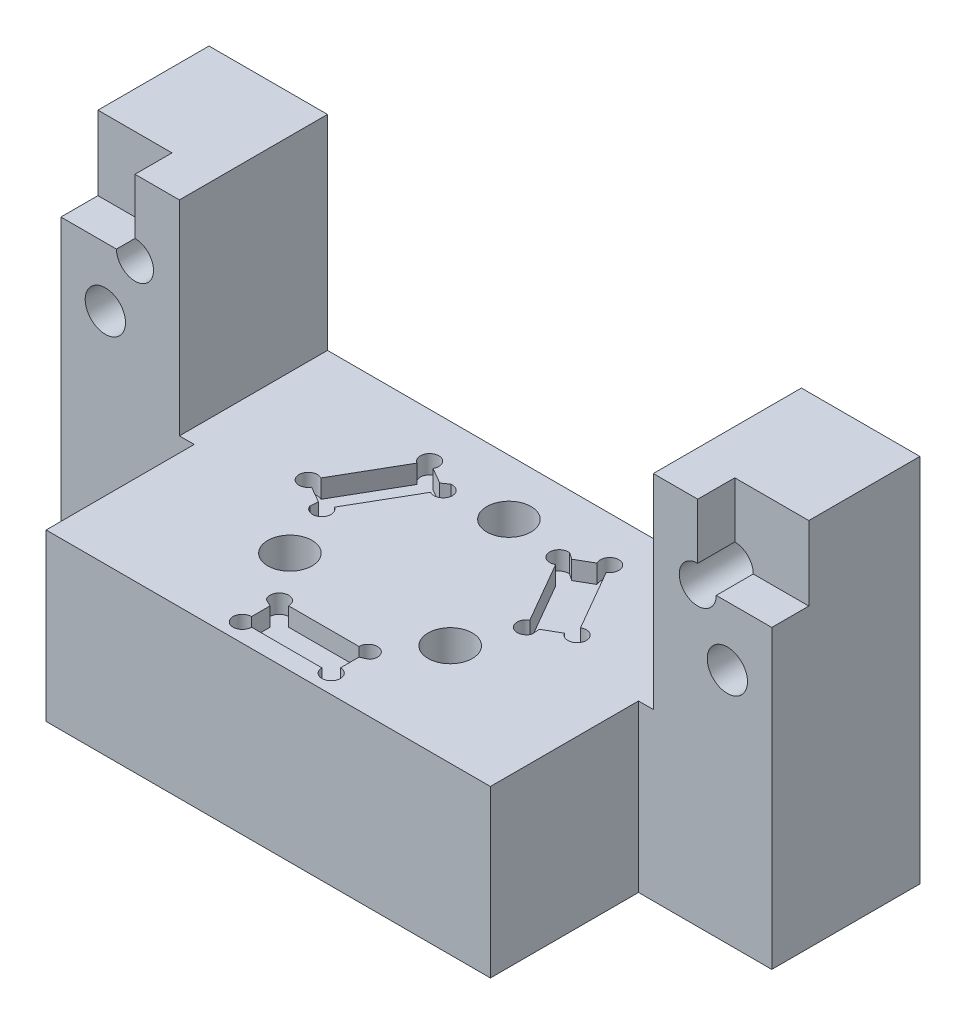
from build123d import *

# Parameters (mm, degrees)
SKETCH1_W                                      = 60.96
SKETCH1_H                                      = 31.75
BOSS_EXTRUDE1_DEPTH                            = 12.7
CUT_EXTRUDE2_REACH                             = 27.4
SKETCH4_W                                      = 40.64
SKETCH4_H                                      = 17.526
SKETCH5_W                                      = 11.43
SKETCH5_H                                      = 31.75
CUT_EXTRUDE3_DEPTH                             = 12.7
SKETCH6_W                                      = 6.35
SKETCH6_H                                      = 6.35
CUT_EXTRUDE4_DEPTH                             = 3.175
SKETCH7_R                                      = 1.5875
CUT_EXTRUDE5_DEPTH                             = 6.35
F_8_32_TAPPED_HOLE1_D                          = 3.4544
F_8_32_TAPPED_HOLE1_DEPTH                      = 12.701
CUT_EXTRUDE7_DEPTH                             = 1.5875
CBORE_FOR_6_SOCKET_HEAD_CAP_SCREW1_D           = 3.7973
CBORE_FOR_6_SOCKET_HEAD_CAP_SCREW1_CBORE_D     = 7.14502
CBORE_FOR_6_SOCKET_HEAD_CAP_SCREW1_CBORE_DEPTH = 3.5052


with BuildPart() as part:
    # Sketch1 → Boss-Extrude1 (new body, symmetric)
    with BuildSketch(Plane.XY):
        Rectangle(SKETCH1_W, SKETCH1_H)
    extrude(amount=BOSS_EXTRUDE1_DEPTH, both=True)

    # Sketch4 → Cut-Extrude2 (cut, up to next)
    with BuildSketch(Plane.XY.offset(12.7), mode=Mode.PRIVATE) as cut_extrude2_sk1:
        with Locations((0, 7.112)):
            Rectangle(SKETCH4_W, SKETCH4_H)
    cut_extrude2_tool1 = extrude(cut_extrude2_sk1.sketch, amount=-CUT_EXTRUDE2_REACH, mode=Mode.PRIVATE) & part.part
    add(cut_extrude2_tool1.solids().sort_by_distance((0, 7.112, 12.7))[0], mode=Mode.SUBTRACT)

    # Sketch5 → Cut-Extrude3 (cut)
    with BuildSketch(Plane.XY.offset(12.7)):
        with Locations((24.765, 0)):
            Rectangle(SKETCH5_W, SKETCH5_H)
    cut_extrude3 = extrude(amount=-CUT_EXTRUDE3_DEPTH, mode=Mode.SUBTRACT)

    # Mirror2: Cut-Extrude3 across plane
    add(cut_extrude3.mirror(Plane(origin=(0, 0, 0), x_dir=(0, 0, 1), z_dir=(1, 0, 0))), mode=Mode.SUBTRACT)

    # Sketch6 → Cut-Extrude4 (cut)
    with BuildSketch(Plane.XY):
        with Locations((27.305, 12.7)):
            Rectangle(SKETCH6_W, SKETCH6_H)
    cut_extrude4 = extrude(amount=-CUT_EXTRUDE4_DEPTH, mode=Mode.SUBTRACT)

    # Sketch7 → Cut-Extrude5 (cut)
    with BuildSketch(Plane.XY):
        with Locations((24.13, 9.525)):
            Circle(SKETCH7_R)
    cut_extrude5 = extrude(amount=-CUT_EXTRUDE5_DEPTH, mode=Mode.SUBTRACT)

    # #8-32 Tapped Hole1
    with Locations(Plane.XY):
        with Locations((26.67, 4.445)):
            f_8_32_tapped_hole1 = Hole(F_8_32_TAPPED_HOLE1_D / 2, depth=F_8_32_TAPPED_HOLE1_DEPTH)

    # Mirror3: Cut-Extrude4, Cut-Extrude5, #8-32 Tapped Hole1 across plane
    add(cut_extrude4.mirror(Plane(origin=(0, 0, 0), x_dir=(0, 0, 1), z_dir=(1, 0, 0))), mode=Mode.SUBTRACT)
    add(cut_extrude5.mirror(Plane(origin=(0, 0, 0), x_dir=(0, 0, 1), z_dir=(1, 0, 0))), mode=Mode.SUBTRACT)
    add(f_8_32_tapped_hole1.mirror(Plane(origin=(0, 0, 0), x_dir=(0, 0, 1), z_dir=(1, 0, 0))), mode=Mode.SUBTRACT)

    # Sketch13 → Cut-Extrude7 (cut)
    with BuildSketch(Plane(origin=(0, -1.651, 0), x_dir=(1, 0, 0), z_dir=(0, 1, 0))):
        with BuildLine():
            ThreePointArc((-3.01625, -7.9375), (-3.247570925, -8.497600525), (-3.80670694, -8.731243169))
            ThreePointArc((-3.80670694, -8.731243169), (0, -9.525), (3.80670694, -8.731243169))
            ThreePointArc((3.80670694, -8.731243169), (3.247570925, -8.497600525), (3.01625, -7.9375))
            Line((3.01625, -7.9375), (-3.01625, -7.9375))
        make_face()
        with BuildLine():
            ThreePointArc((-3.81, -10.31875), (-3.248733992, -10.551233992), (-3.01625, -11.1125))
            Line((-3.01625, -11.1125), (3.01625, -11.1125))
            ThreePointArc((3.01625, -11.1125), (3.248733992, -10.551233992), (3.81, -10.31875))
            Line((3.81, -10.31875), (3.81, -8.73125))
            ThreePointArc((3.81, -8.73125), (3.808353466, -8.731248292), (3.80670694, -8.731243169))
            ThreePointArc((3.80670694, -8.731243169), (0, -9.525), (-3.80670694, -8.731243169))
            ThreePointArc((-3.80670694, -8.731243169), (-3.808353466, -8.731248292), (-3.81, -8.73125))
            Line((-3.81, -8.73125), (-3.81, -10.31875))
        make_face()
        with BuildLine():
            ThreePointArc((-4.431365232, -8.431407189), (-4.123382809, -8.586229627), (-3.81, -8.729806699))
            Line((-3.81, -8.729806699), (-3.81, -7.9375))
            Line((-3.81, -7.9375), (-3.01625, -7.9375))
            ThreePointArc((-3.01625, -7.9375), (-4.071563004, -7.188084322), (-4.431365232, -8.431407189))
        make_face()
        with BuildLine():
            Line((-3.81, -7.9375), (-3.81, -8.729806699))
            ThreePointArc((-3.81, -8.729806699), (-3.808353538, -8.730525089), (-3.80670694, -8.731243169))
            ThreePointArc((-3.80670694, -8.731243169), (-3.247570925, -8.497600525), (-3.01625, -7.9375))
            Line((-3.01625, -7.9375), (-3.81, -7.9375))
        make_face()
        with BuildLine():
            ThreePointArc((-4.431365232, -8.431407189), (-4.123382809, -8.586229627), (-3.81, -8.729806699))
            Line((-3.81, -8.729806699), (-3.81, -7.9375))
            Line((-3.81, -7.9375), (-3.01625, -7.9375))
            ThreePointArc((-3.01625, -7.9375), (-4.071563004, -7.188084322), (-4.431365232, -8.431407189))
        make_face()
        with BuildLine():
            Line((-3.81, -7.9375), (-3.81, -8.729806699))
            ThreePointArc((-3.81, -8.729806699), (-3.808353538, -8.730525089), (-3.80670694, -8.731243169))
            ThreePointArc((-3.80670694, -8.731243169), (-3.247570925, -8.497600525), (-3.01625, -7.9375))
            Line((-3.01625, -7.9375), (-3.81, -7.9375))
        make_face()
        with BuildLine():
            Line((-3.81, -10.31875), (-3.81, -11.1125))
            Line((-3.81, -11.1125), (-3.01625, -11.1125))
            ThreePointArc((-3.01625, -11.1125), (-3.248733992, -10.551233992), (-3.81, -10.31875))
        make_face()
        with BuildLine():
            Line((-3.01625, -11.1125), (-3.81, -11.1125))
            Line((-3.81, -11.1125), (-3.81, -10.31875))
            ThreePointArc((-3.81, -10.31875), (-4.371266008, -11.673766008), (-3.01625, -11.1125))
        make_face()
        with BuildLine():
            Line((-3.81, -10.31875), (-3.81, -11.1125))
            Line((-3.81, -11.1125), (-3.01625, -11.1125))
            ThreePointArc((-3.01625, -11.1125), (-3.248733992, -10.551233992), (-3.81, -10.31875))
        make_face()
        with BuildLine():
            Line((-3.01625, -11.1125), (-3.81, -11.1125))
            Line((-3.81, -11.1125), (-3.81, -10.31875))
            ThreePointArc((-3.81, -10.31875), (-4.371266008, -11.673766008), (-3.01625, -11.1125))
        make_face()
        with BuildLine():
            ThreePointArc((3.81, -10.31875), (3.248733992, -10.551233992), (3.01625, -11.1125))
            Line((3.01625, -11.1125), (3.81, -11.1125))
            Line((3.81, -11.1125), (3.81, -10.31875))
        make_face()
        with BuildLine():
            Line((3.81, -11.1125), (3.01625, -11.1125))
            ThreePointArc((3.01625, -11.1125), (3.81, -11.90625), (4.60375, -11.1125))
            ThreePointArc((4.60375, -11.1125), (4.371266008, -10.551233992), (3.81, -10.31875))
            Line((3.81, -10.31875), (3.81, -11.1125))
        make_face()
        with BuildLine():
            ThreePointArc((3.81, -10.31875), (3.248733992, -10.551233992), (3.01625, -11.1125))
            Line((3.01625, -11.1125), (3.81, -11.1125))
            Line((3.81, -11.1125), (3.81, -10.31875))
        make_face()
        with BuildLine():
            Line((3.81, -11.1125), (3.01625, -11.1125))
            ThreePointArc((3.01625, -11.1125), (3.81, -11.90625), (4.60375, -11.1125))
            ThreePointArc((4.60375, -11.1125), (4.371266008, -10.551233992), (3.81, -10.31875))
            Line((3.81, -10.31875), (3.81, -11.1125))
        make_face()
        with BuildLine():
            ThreePointArc((3.01625, -7.9375), (3.247570925, -8.497600525), (3.80670694, -8.731243169))
            ThreePointArc((3.80670694, -8.731243169), (3.808353538, -8.730525089), (3.81, -8.729806699))
            Line((3.81, -8.729806699), (3.81, -7.9375))
            Line((3.81, -7.9375), (3.01625, -7.9375))
        make_face()
        with BuildLine():
            Line((3.81, -7.9375), (3.81, -8.729806699))
            ThreePointArc((3.81, -8.729806699), (4.123382809, -8.586229627), (4.431365232, -8.431407189))
            ThreePointArc((4.431365232, -8.431407189), (4.559415678, -8.199063004), (4.60375, -7.9375))
            ThreePointArc((4.60375, -7.9375), (3.81, -7.14375), (3.01625, -7.9375))
            Line((3.01625, -7.9375), (3.81, -7.9375))
        make_face()
        with BuildLine():
            ThreePointArc((3.01625, -7.9375), (3.247570925, -8.497600525), (3.80670694, -8.731243169))
            ThreePointArc((3.80670694, -8.731243169), (3.808353538, -8.730525089), (3.81, -8.729806699))
            Line((3.81, -8.729806699), (3.81, -7.9375))
            Line((3.81, -7.9375), (3.01625, -7.9375))
        make_face()
        with BuildLine():
            Line((3.81, -7.9375), (3.81, -8.729806699))
            ThreePointArc((3.81, -8.729806699), (4.123382809, -8.586229627), (4.431365232, -8.431407189))
            ThreePointArc((4.431365232, -8.431407189), (4.559415678, -8.199063004), (4.60375, -7.9375))
            ThreePointArc((4.60375, -7.9375), (3.81, -7.14375), (3.01625, -7.9375))
            Line((3.01625, -7.9375), (3.81, -7.9375))
        make_face()
        with BuildLine():
            ThreePointArc((9.464831861, 1.06891667), (9.465659561, 1.067493298), (9.466484307, 1.066068212))
            Line((9.466484307, 1.066068212), (10.841299635, 1.859818212))
            ThreePointArc((10.841299635, 1.859818212), (10.762003675, 2.462130829), (11.1318323, 2.944100876))
            Line((11.1318323, 2.944100876), (8.1155823, 8.168399124))
            ThreePointArc((8.1155823, 8.168399124), (7.513269683, 8.089103164), (7.031299635, 8.458931788))
            Line((7.031299635, 8.458931788), (5.656484307, 7.665181788))
            ThreePointArc((5.656484307, 7.665181788), (5.657306095, 7.663754995), (5.658124921, 7.662326499))
            ThreePointArc((5.658124921, 7.662326499), (8.248891971, 4.7625), (9.464831861, 1.06891667))
        make_face()
        with BuildLine():
            Line((5.365951643, 6.580899124), (8.382201643, 1.356600876))
            ThreePointArc((8.382201643, 1.356600876), (8.982923388, 1.436321341), (9.464831861, 1.06891667))
            ThreePointArc((9.464831861, 1.06891667), (8.248891971, 4.7625), (5.658124921, 7.662326499))
            ThreePointArc((5.658124921, 7.662326499), (5.736204772, 7.472153534), (5.762826643, 7.268306788))
            ThreePointArc((5.762826643, 7.268306788), (5.656484307, 6.871431788), (5.365951643, 6.580899124))
        make_face()
        with BuildLine():
            ThreePointArc((11.1318323, 2.944100876), (10.762003675, 2.462130829), (10.841299635, 1.859818212))
            Line((10.841299635, 1.859818212), (11.5287073, 2.256693212))
            Line((11.5287073, 2.256693212), (11.1318323, 2.944100876))
        make_face()
        with BuildLine():
            Line((11.5287073, 2.256693212), (10.841299635, 1.859818212))
            ThreePointArc((10.841299635, 1.859818212), (11.734144917, 1.489989587), (12.3224573, 2.256693212))
            ThreePointArc((12.3224573, 2.256693212), (11.9255823, 2.944100876), (11.1318323, 2.944100876))
            Line((11.1318323, 2.944100876), (11.5287073, 2.256693212))
        make_face()
        with BuildLine():
            ThreePointArc((11.1318323, 2.944100876), (10.762003675, 2.462130829), (10.841299635, 1.859818212))
            Line((10.841299635, 1.859818212), (11.5287073, 2.256693212))
            Line((11.5287073, 2.256693212), (11.1318323, 2.944100876))
        make_face()
        with BuildLine():
            Line((11.5287073, 2.256693212), (10.841299635, 1.859818212))
            ThreePointArc((10.841299635, 1.859818212), (11.734144917, 1.489989587), (12.3224573, 2.256693212))
            ThreePointArc((12.3224573, 2.256693212), (11.9255823, 2.944100876), (11.1318323, 2.944100876))
            Line((11.1318323, 2.944100876), (11.5287073, 2.256693212))
        make_face()
        with BuildLine():
            ThreePointArc((7.031299635, 8.458931788), (7.513269683, 8.089103164), (8.1155823, 8.168399124))
            Line((8.1155823, 8.168399124), (7.7187073, 8.855806788))
            Line((7.7187073, 8.855806788), (7.031299635, 8.458931788))
        make_face()
        with BuildLine():
            Line((7.7187073, 8.855806788), (8.1155823, 8.168399124))
            ThreePointArc((8.1155823, 8.168399124), (8.406114964, 8.458931788), (8.5124573, 8.855806788))
            ThreePointArc((8.5124573, 8.855806788), (7.513269683, 9.622510413), (7.031299635, 8.458931788))
            Line((7.031299635, 8.458931788), (7.7187073, 8.855806788))
        make_face()
        with BuildLine():
            ThreePointArc((7.031299635, 8.458931788), (7.513269683, 8.089103164), (8.1155823, 8.168399124))
            Line((8.1155823, 8.168399124), (7.7187073, 8.855806788))
            Line((7.7187073, 8.855806788), (7.031299635, 8.458931788))
        make_face()
        with BuildLine():
            Line((7.7187073, 8.855806788), (8.1155823, 8.168399124))
            ThreePointArc((8.1155823, 8.168399124), (8.406114964, 8.458931788), (8.5124573, 8.855806788))
            ThreePointArc((8.5124573, 8.855806788), (7.513269683, 9.622510413), (7.031299635, 8.458931788))
            Line((7.031299635, 8.458931788), (7.7187073, 8.855806788))
        make_face()
        with BuildLine():
            ThreePointArc((5.086130199, 8.053378459), (4.189282126, 7.120119155), (5.365951643, 6.580899124))
            Line((5.365951643, 6.580899124), (4.969076643, 7.268306788))
            Line((4.969076643, 7.268306788), (5.655234371, 7.664460138))
            ThreePointArc((5.655234371, 7.664460138), (5.374201575, 7.864069076), (5.086130199, 8.053378459))
        make_face()
        with BuildLine():
            Line((4.969076643, 7.268306788), (5.365951643, 6.580899124))
            ThreePointArc((5.365951643, 6.580899124), (5.656484307, 6.871431788), (5.762826643, 7.268306788))
            ThreePointArc((5.762826643, 7.268306788), (5.736204772, 7.472153534), (5.658124921, 7.662326499))
            ThreePointArc((5.658124921, 7.662326499), (5.656679747, 7.663393455), (5.655234371, 7.664460138))
            Line((5.655234371, 7.664460138), (4.969076643, 7.268306788))
        make_face()
        with BuildLine():
            ThreePointArc((5.086130199, 8.053378459), (4.189282126, 7.120119155), (5.365951643, 6.580899124))
            Line((5.365951643, 6.580899124), (4.969076643, 7.268306788))
            Line((4.969076643, 7.268306788), (5.655234371, 7.664460138))
            ThreePointArc((5.655234371, 7.664460138), (5.374201575, 7.864069076), (5.086130199, 8.053378459))
        make_face()
        with BuildLine():
            Line((4.969076643, 7.268306788), (5.365951643, 6.580899124))
            ThreePointArc((5.365951643, 6.580899124), (5.656484307, 6.871431788), (5.762826643, 7.268306788))
            ThreePointArc((5.762826643, 7.268306788), (5.736204772, 7.472153534), (5.658124921, 7.662326499))
            ThreePointArc((5.658124921, 7.662326499), (5.656679747, 7.663393455), (5.655234371, 7.664460138))
            Line((5.655234371, 7.664460138), (4.969076643, 7.268306788))
        make_face()
        with BuildLine():
            ThreePointArc((8.382201643, 1.356600876), (8.26084513, 0.067965167), (9.517495431, 0.37802873))
            ThreePointArc((9.517495431, 0.37802873), (9.497584384, 0.722160552), (9.465234371, 1.065346561))
            Line((9.465234371, 1.065346561), (8.779076643, 0.669193212))
            Line((8.779076643, 0.669193212), (8.382201643, 1.356600876))
        make_face()
        with BuildLine():
            Line((8.779076643, 0.669193212), (9.465234371, 1.065346561))
            ThreePointArc((9.465234371, 1.065346561), (9.465033284, 1.067131634), (9.464831861, 1.06891667))
            ThreePointArc((9.464831861, 1.06891667), (8.982923388, 1.436321341), (8.382201643, 1.356600876))
            Line((8.382201643, 1.356600876), (8.779076643, 0.669193212))
        make_face()
        with BuildLine():
            ThreePointArc((8.382201643, 1.356600876), (8.26084513, 0.067965167), (9.517495431, 0.37802873))
            ThreePointArc((9.517495431, 0.37802873), (9.497584384, 0.722160552), (9.465234371, 1.065346561))
            Line((9.465234371, 1.065346561), (8.779076643, 0.669193212))
            Line((8.779076643, 0.669193212), (8.382201643, 1.356600876))
        make_face()
        with BuildLine():
            Line((8.779076643, 0.669193212), (9.465234371, 1.065346561))
            ThreePointArc((9.465234371, 1.065346561), (9.465033284, 1.067131634), (9.464831861, 1.06891667))
            ThreePointArc((9.464831861, 1.06891667), (8.982923388, 1.436321341), (8.382201643, 1.356600876))
            Line((8.382201643, 1.356600876), (8.779076643, 0.669193212))
        make_face()
        with BuildLine():
            ThreePointArc((-5.658124921, 7.662326499), (-8.248891971, 4.7625), (-9.464831861, 1.06891667))
            ThreePointArc((-9.464831861, 1.06891667), (-8.982923388, 1.436321341), (-8.382201643, 1.356600876))
            Line((-8.382201643, 1.356600876), (-5.365951643, 6.580899124))
            ThreePointArc((-5.365951643, 6.580899124), (-5.735352463, 7.061279184), (-5.658124921, 7.662326499))
        make_face()
        with BuildLine():
            Line((-10.841299635, 1.859818212), (-9.466484307, 1.066068212))
            ThreePointArc((-9.466484307, 1.066068212), (-9.465659561, 1.067493298), (-9.464831861, 1.06891667))
            ThreePointArc((-9.464831861, 1.06891667), (-8.248891971, 4.7625), (-5.658124921, 7.662326499))
            ThreePointArc((-5.658124921, 7.662326499), (-5.657306095, 7.663754995), (-5.656484307, 7.665181788))
            Line((-5.656484307, 7.665181788), (-7.031299635, 8.458931788))
            ThreePointArc((-7.031299635, 8.458931788), (-7.513269683, 8.089103164), (-8.1155823, 8.168399124))
            Line((-8.1155823, 8.168399124), (-11.1318323, 2.944100876))
            ThreePointArc((-11.1318323, 2.944100876), (-10.841299635, 2.653568212), (-10.7349573, 2.256693212))
            ThreePointArc((-10.7349573, 2.256693212), (-10.762003675, 2.051255595), (-10.841299635, 1.859818212))
        make_face()
        with BuildLine():
            ThreePointArc((-5.655234371, 7.664460138), (-5.656679747, 7.663393455), (-5.658124921, 7.662326499))
            ThreePointArc((-5.658124921, 7.662326499), (-5.735352463, 7.061279184), (-5.365951643, 6.580899124))
            Line((-5.365951643, 6.580899124), (-4.969076643, 7.268306788))
            Line((-4.969076643, 7.268306788), (-5.655234371, 7.664460138))
        make_face()
        with BuildLine():
            Line((-4.969076643, 7.268306788), (-5.365951643, 6.580899124))
            ThreePointArc((-5.365951643, 6.580899124), (-4.572201643, 6.580899124), (-4.175326643, 7.268306788))
            ThreePointArc((-4.175326643, 7.268306788), (-4.45084513, 7.869534833), (-5.086130199, 8.053378459))
            ThreePointArc((-5.086130199, 8.053378459), (-5.374201575, 7.864069076), (-5.655234371, 7.664460138))
            Line((-5.655234371, 7.664460138), (-4.969076643, 7.268306788))
        make_face()
        with BuildLine():
            ThreePointArc((-5.655234371, 7.664460138), (-5.656679747, 7.663393455), (-5.658124921, 7.662326499))
            ThreePointArc((-5.658124921, 7.662326499), (-5.735352463, 7.061279184), (-5.365951643, 6.580899124))
            Line((-5.365951643, 6.580899124), (-4.969076643, 7.268306788))
            Line((-4.969076643, 7.268306788), (-5.655234371, 7.664460138))
        make_face()
        with BuildLine():
            Line((-4.969076643, 7.268306788), (-5.365951643, 6.580899124))
            ThreePointArc((-5.365951643, 6.580899124), (-4.572201643, 6.580899124), (-4.175326643, 7.268306788))
            ThreePointArc((-4.175326643, 7.268306788), (-4.45084513, 7.869534833), (-5.086130199, 8.053378459))
            ThreePointArc((-5.086130199, 8.053378459), (-5.374201575, 7.864069076), (-5.655234371, 7.664460138))
            Line((-5.655234371, 7.664460138), (-4.969076643, 7.268306788))
        make_face()
        with BuildLine():
            ThreePointArc((-9.465234371, 1.065346561), (-9.497584384, 0.722160552), (-9.517495431, 0.37802873))
            ThreePointArc((-9.517495431, 0.37802873), (-8.63088901, -0.110601305), (-7.985326643, 0.669193212))
            ThreePointArc((-7.985326643, 0.669193212), (-8.091668978, 1.066068212), (-8.382201643, 1.356600876))
            Line((-8.382201643, 1.356600876), (-8.779076643, 0.669193212))
            Line((-8.779076643, 0.669193212), (-9.465234371, 1.065346561))
        make_face()
        with BuildLine():
            ThreePointArc((-9.464831861, 1.06891667), (-9.465033284, 1.067131634), (-9.465234371, 1.065346561))
            Line((-9.465234371, 1.065346561), (-8.779076643, 0.669193212))
            Line((-8.779076643, 0.669193212), (-8.382201643, 1.356600876))
            ThreePointArc((-8.382201643, 1.356600876), (-8.982923388, 1.436321341), (-9.464831861, 1.06891667))
        make_face()
        with BuildLine():
            ThreePointArc((-9.465234371, 1.065346561), (-9.497584384, 0.722160552), (-9.517495431, 0.37802873))
            ThreePointArc((-9.517495431, 0.37802873), (-8.63088901, -0.110601305), (-7.985326643, 0.669193212))
            ThreePointArc((-7.985326643, 0.669193212), (-8.091668978, 1.066068212), (-8.382201643, 1.356600876))
            Line((-8.382201643, 1.356600876), (-8.779076643, 0.669193212))
            Line((-8.779076643, 0.669193212), (-9.465234371, 1.065346561))
        make_face()
        with BuildLine():
            ThreePointArc((-9.464831861, 1.06891667), (-9.465033284, 1.067131634), (-9.465234371, 1.065346561))
            Line((-9.465234371, 1.065346561), (-8.779076643, 0.669193212))
            Line((-8.779076643, 0.669193212), (-8.382201643, 1.356600876))
            ThreePointArc((-8.382201643, 1.356600876), (-8.982923388, 1.436321341), (-9.464831861, 1.06891667))
        make_face()
        with BuildLine():
            ThreePointArc((-11.1318323, 2.944100876), (-12.295410924, 2.051255595), (-10.841299635, 1.859818212))
            Line((-10.841299635, 1.859818212), (-11.5287073, 2.256693212))
            Line((-11.5287073, 2.256693212), (-11.1318323, 2.944100876))
        make_face()
        with BuildLine():
            Line((-11.5287073, 2.256693212), (-10.841299635, 1.859818212))
            ThreePointArc((-10.841299635, 1.859818212), (-10.762003675, 2.051255595), (-10.7349573, 2.256693212))
            ThreePointArc((-10.7349573, 2.256693212), (-10.841299635, 2.653568212), (-11.1318323, 2.944100876))
            Line((-11.1318323, 2.944100876), (-11.5287073, 2.256693212))
        make_face()
        with BuildLine():
            ThreePointArc((-11.1318323, 2.944100876), (-12.295410924, 2.051255595), (-10.841299635, 1.859818212))
            Line((-10.841299635, 1.859818212), (-11.5287073, 2.256693212))
            Line((-11.5287073, 2.256693212), (-11.1318323, 2.944100876))
        make_face()
        with BuildLine():
            Line((-11.5287073, 2.256693212), (-10.841299635, 1.859818212))
            ThreePointArc((-10.841299635, 1.859818212), (-10.762003675, 2.051255595), (-10.7349573, 2.256693212))
            ThreePointArc((-10.7349573, 2.256693212), (-10.841299635, 2.653568212), (-11.1318323, 2.944100876))
            Line((-11.1318323, 2.944100876), (-11.5287073, 2.256693212))
        make_face()
        with BuildLine():
            ThreePointArc((-6.9249573, 8.855806788), (-8.1155823, 9.543214453), (-8.1155823, 8.168399124))
            Line((-8.1155823, 8.168399124), (-7.7187073, 8.855806788))
            Line((-7.7187073, 8.855806788), (-7.031299635, 8.458931788))
            ThreePointArc((-7.031299635, 8.458931788), (-6.952003675, 8.650369171), (-6.9249573, 8.855806788))
        make_face()
        with BuildLine():
            Line((-7.7187073, 8.855806788), (-8.1155823, 8.168399124))
            ThreePointArc((-8.1155823, 8.168399124), (-7.513269683, 8.089103164), (-7.031299635, 8.458931788))
            Line((-7.031299635, 8.458931788), (-7.7187073, 8.855806788))
        make_face()
        with BuildLine():
            ThreePointArc((-6.9249573, 8.855806788), (-8.1155823, 9.543214453), (-8.1155823, 8.168399124))
            Line((-8.1155823, 8.168399124), (-7.7187073, 8.855806788))
            Line((-7.7187073, 8.855806788), (-7.031299635, 8.458931788))
            ThreePointArc((-7.031299635, 8.458931788), (-6.952003675, 8.650369171), (-6.9249573, 8.855806788))
        make_face()
        with BuildLine():
            Line((-7.7187073, 8.855806788), (-8.1155823, 8.168399124))
            ThreePointArc((-8.1155823, 8.168399124), (-7.513269683, 8.089103164), (-7.031299635, 8.458931788))
            Line((-7.031299635, 8.458931788), (-7.7187073, 8.855806788))
        make_face()
    extrude(amount=-CUT_EXTRUDE7_DEPTH, mode=Mode.SUBTRACT)

    # CBORE for #6 Socket Head Cap Screw1 (through all)
    with Locations(Plane(origin=(0, -15.875, 0), x_dir=(-1, 0, 0), z_dir=(0, -1, 0))):
        with Locations((0, 7.9375), (6.874076643, -3.96875), (-6.874076643, -3.96875)):
            CounterBoreHole(CBORE_FOR_6_SOCKET_HEAD_CAP_SCREW1_D / 2, CBORE_FOR_6_SOCKET_HEAD_CAP_SCREW1_CBORE_D / 2, CBORE_FOR_6_SOCKET_HEAD_CAP_SCREW1_CBORE_DEPTH)


solid = part.part
